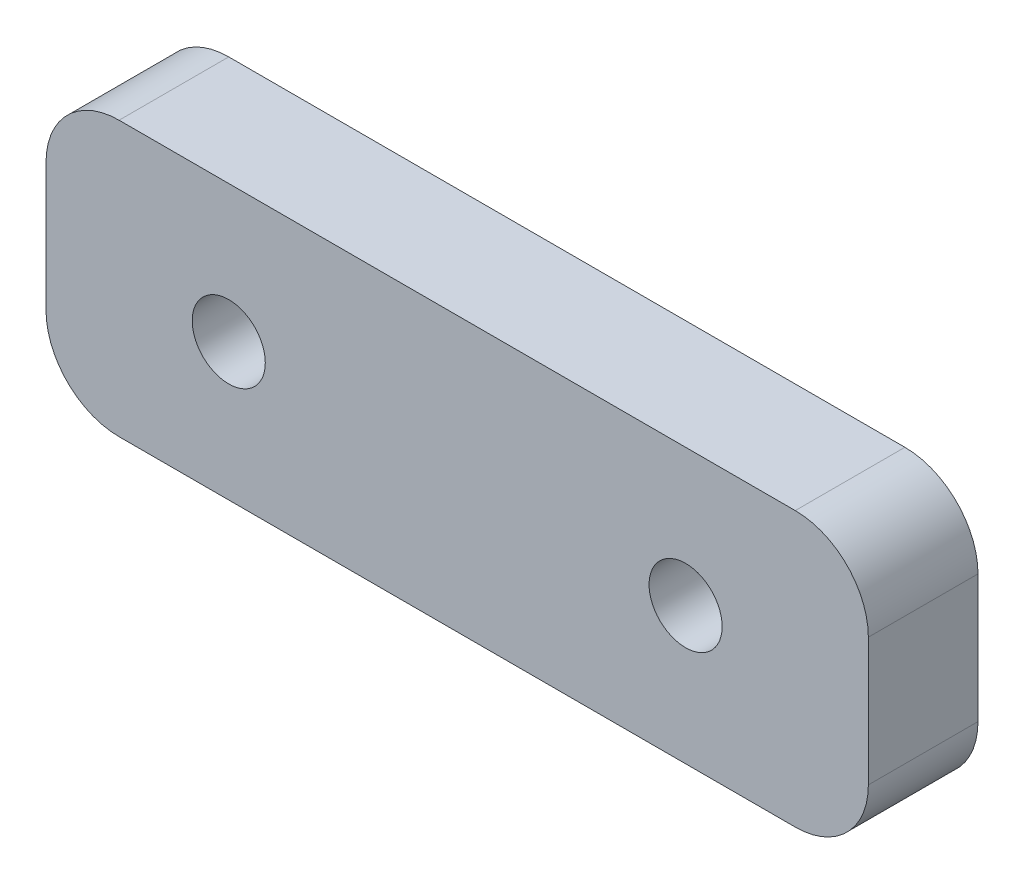
from build123d import *

# Parameters (mm, degrees)
SKETCH1_W           = 45
SKETCH1_H           = 15
SKETCH1_R           = 2
BOSS_EXTRUDE1_DEPTH = 6
FILLET1_R           = 4


with BuildPart() as part:
    # Sketch1 → Boss-Extrude1 (new body)
    with BuildSketch(Plane.XY):
        with Locations((12.5, 0)):
            Rectangle(SKETCH1_W, SKETCH1_H)
        Circle(SKETCH1_R, mode=Mode.SUBTRACT)
        with Locations((25, 0)):
            Circle(SKETCH1_R, mode=Mode.SUBTRACT)
    extrude(amount=BOSS_EXTRUDE1_DEPTH)

    # Fillet1
    fillet1_edges = [part.edges().sort_by_distance(p)[0] for p in [
        (-10, 7.5, 3),
        (35, 7.5, 3),
        (35, -7.5, 3),
        (-10, -7.5, 3),
    ]]
    fillet(fillet1_edges, radius=FILLET1_R)


solid = part.part
